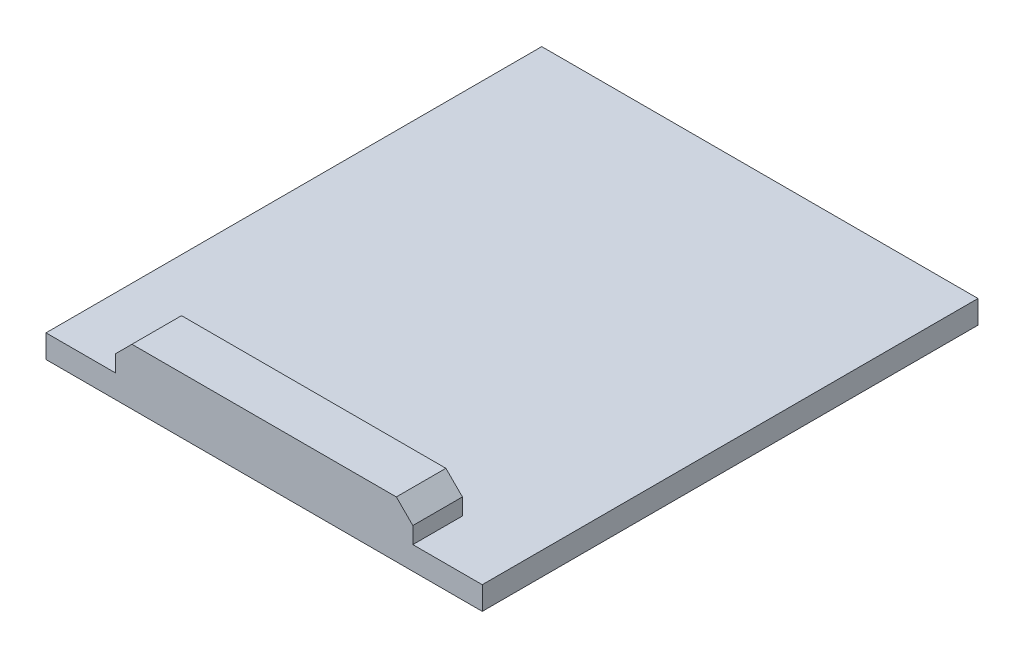
from build123d import *

# Parameters (mm, degrees)
SKETCH1_W           = 26.4
SKETCH1_H           = 1.4
BOSS_EXTRUDE1_DEPTH = 30
BOSS_EXTRUDE2_DEPTH = 3


with BuildPart() as part:
    # Sketch1 → Boss-Extrude1 (new body)
    with BuildSketch(Plane.XY):
        with Locations((13.2, 0.7)):
            Rectangle(SKETCH1_W, SKETCH1_H)
    extrude(amount=BOSS_EXTRUDE1_DEPTH)

    # Sketch2 → Boss-Extrude2 (add)
    with BuildSketch(Plane.XY.offset(30)):
        Polygon((4.2, 1.4), (4.2, 2.4), (5.2, 3.4), (21.2, 3.4), (22.2, 2.4), (22.2, 1.4), align=None)
    extrude(amount=-BOSS_EXTRUDE2_DEPTH)


solid = part.part
